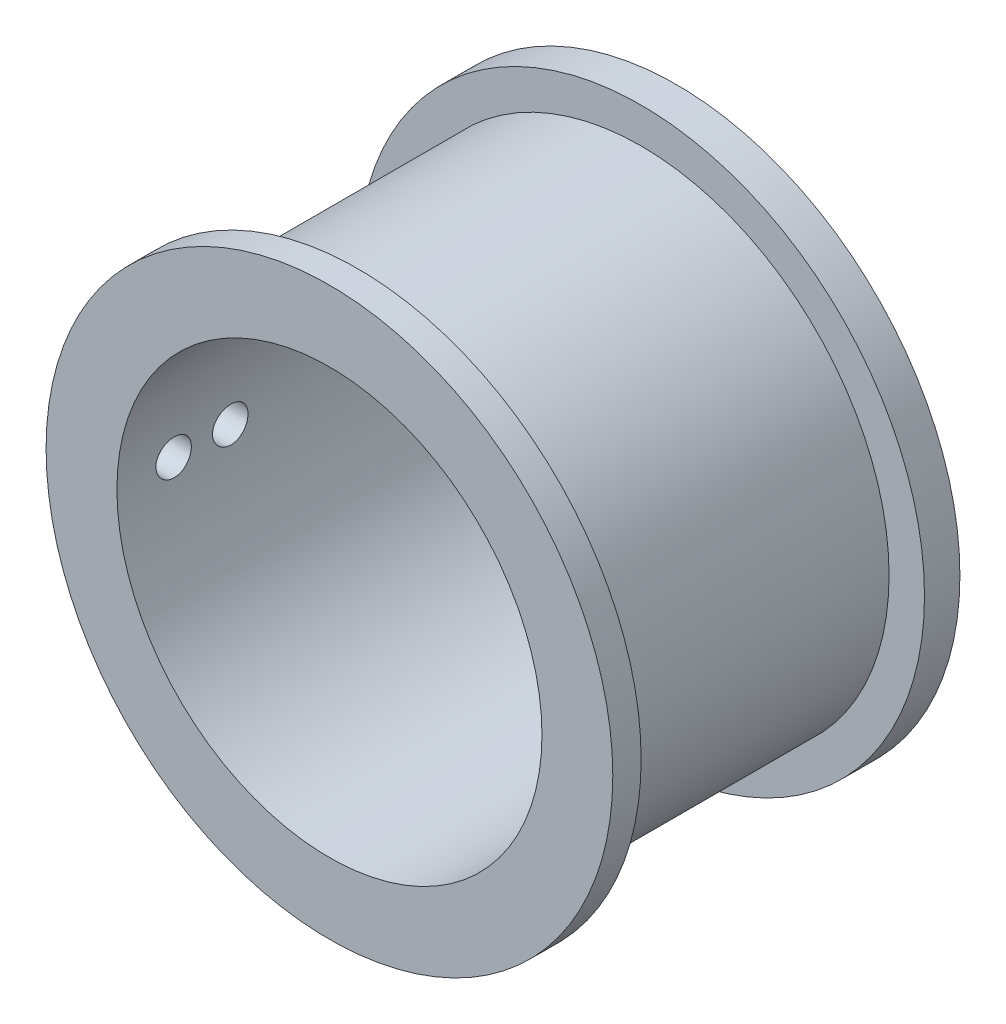
from build123d import *

# Parameters (mm, degrees)
SKETCH1_R           = 25.4
SKETCH1_R_2         = 1.7
BOSS_EXTRUDE1_DEPTH = 3.175
SKETCH4_R           = 22.225
SKETCH4_R_2         = 19.05
BOSS_EXTRUDE2_DEPTH = 25.4
SKETCH5_R           = 25.4
SKETCH5_R_2         = 19.05
BOSS_EXTRUDE3_DEPTH = 2.54
SKETCH6_R           = 1.5875
CUT_EXTRUDE1_DEPTH  = 26.4


with BuildPart() as part:
    # Sketch1 → Boss-Extrude1 (new body)
    with BuildSketch(Plane.XY):
        Circle(SKETCH1_R)
        with Locations((0, -8.001)):
            Circle(SKETCH1_R_2, mode=Mode.SUBTRACT)
        with Locations((0, 8.001)):
            Circle(SKETCH1_R_2, mode=Mode.SUBTRACT)
        with Locations((-6.929069256, 4.0005)):
            Circle(SKETCH1_R_2, mode=Mode.SUBTRACT)
        with Locations((-6.929069256, -4.0005)):
            Circle(SKETCH1_R_2, mode=Mode.SUBTRACT)
        with Locations((6.929069256, -4.0005)):
            Circle(SKETCH1_R_2, mode=Mode.SUBTRACT)
        with Locations((6.929069256, 4.0005)):
            Circle(SKETCH1_R_2, mode=Mode.SUBTRACT)
    extrude(amount=BOSS_EXTRUDE1_DEPTH)

    # Sketch4 → Boss-Extrude2 (add)
    with BuildSketch(Plane.XY.offset(3.175)):
        Circle(SKETCH4_R)
        Circle(SKETCH4_R_2, mode=Mode.SUBTRACT)
    extrude(amount=BOSS_EXTRUDE2_DEPTH)

    # Sketch5 → Boss-Extrude3 (add)
    with BuildSketch(Plane.XY.offset(28.575)):
        Circle(SKETCH5_R)
        Circle(SKETCH5_R_2, mode=Mode.SUBTRACT)
    extrude(amount=BOSS_EXTRUDE3_DEPTH)

    # Sketch6 → Cut-Extrude1 (cut, through all)
    with BuildSketch(Plane(origin=(0, 0, 0), x_dir=(0, 0, -1), z_dir=(1, 0, 0))):
        with Locations((-26.035, 0)):
            Circle(SKETCH6_R)
        with Locations((-20.955, 0)):
            Circle(SKETCH6_R)
    extrude(amount=-CUT_EXTRUDE1_DEPTH, mode=Mode.SUBTRACT)


solid = part.part
